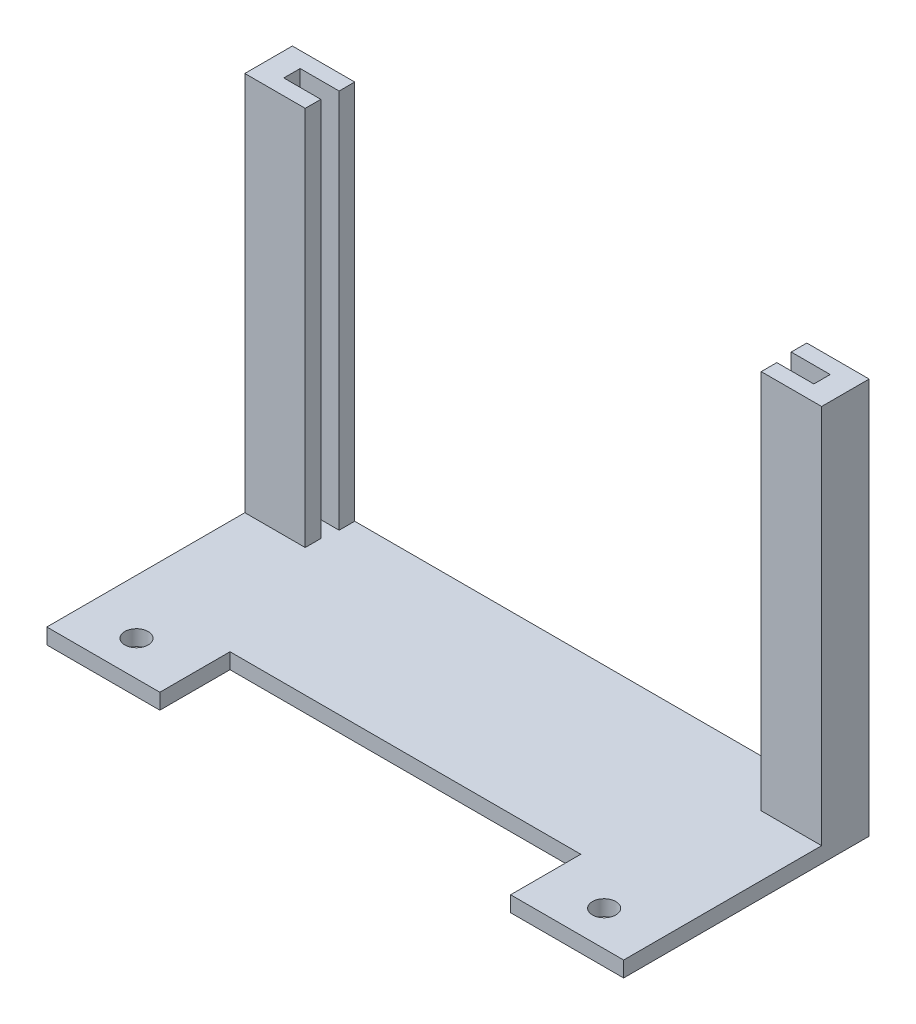
from build123d import *

# Parameters (mm, degrees)
SKETCH1_R           = 1.5
BOSS_EXTRUDE1_DEPTH = 2
BOSS_EXTRUDE2_DEPTH = 50.8


with BuildPart() as part:
    # Sketch1 → Boss-Extrude1 (new body)
    with BuildSketch(Plane(origin=(0, 0, 0), x_dir=(1, 0, 0), z_dir=(0, 1, 0))):
        Polygon((-37, 15.75), (-37, -15.75), (-22.5, -15.75), (-22.5, -6.75), (22.5, -6.75), (22.5, -15.75), (37, -15.75), (37, 15.75), align=None)
        with Locations((-30, -11.25)):
            Circle(SKETCH1_R, mode=Mode.SUBTRACT)
        with Locations((30, -11.25)):
            Circle(SKETCH1_R, mode=Mode.SUBTRACT)
    extrude(amount=BOSS_EXTRUDE1_DEPTH)

    # Sketch1_3 → Boss-Extrude2 (add)
    with BuildSketch(Plane(origin=(0, 0, 0), x_dir=(1, 0, 0), z_dir=(0, 1, 0))):
        Polygon((-29, 13.75), (-29, 15.75), (-37, 15.75), (-37, 9.65), (-29.25, 9.65), (-29.25, 11.65), (-34, 11.65), (-34, 13.75), align=None)
        Polygon((37, 15.75), (29, 15.75), (29, 13.75), (34, 13.75), (34, 11.65), (29.25, 11.65), (29.25, 9.65), (37, 9.65), align=None)
    extrude(amount=BOSS_EXTRUDE2_DEPTH)


solid = part.part
